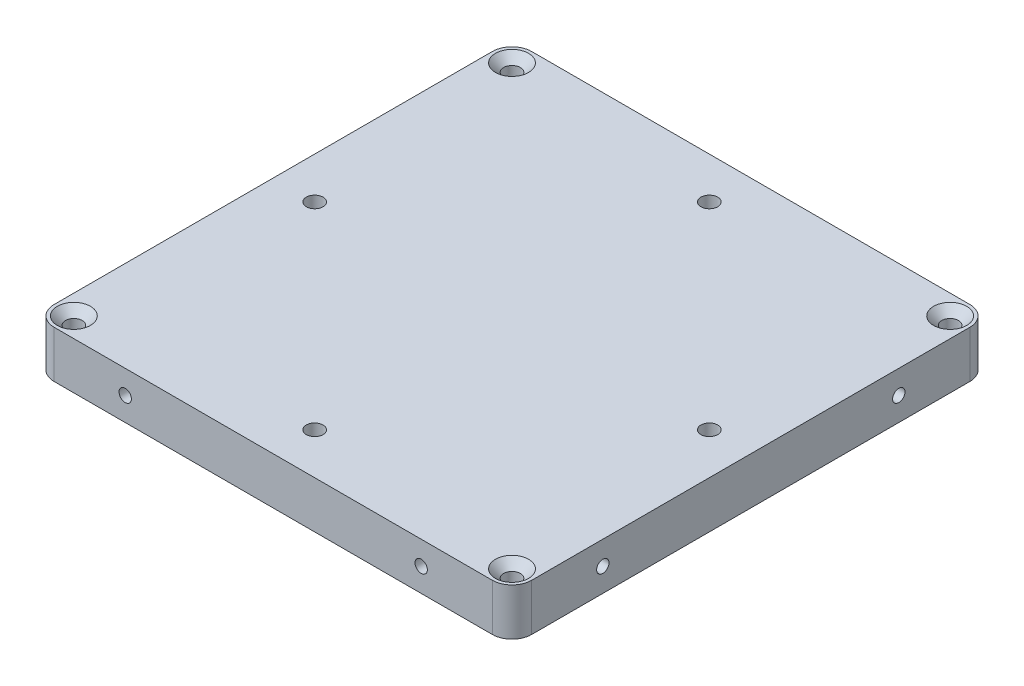
from build123d import *

# Parameters (mm, degrees)
SKETCH1_W                     = 96.825
SKETCH1_H                     = 96.825
BOSS_EXTRUDE1_DEPTH           = 4.7625
FILLET1_R                     = 4
CSK_FOR_M3_SFHCS2_D           = 3.4
CSK_FOR_M3_SFHCS2_CSINK_D     = 6.72
CSK_FOR_M3_SFHCS2_CSINK_ANGLE = 90
CSK_FOR_M3_SFHCS1_D           = 3.4
CSK_FOR_M3_SFHCS1_DEPTH       = 35
CSK_FOR_M3_SFHCS1_CSINK_D     = 6.72
CSK_FOR_M3_SFHCS1_CSINK_ANGLE = 90
CSK_FOR_M3_SFHCS1_TIP         = 1.021463052
M3X0_5_TAPPED_HOLE1_D         = 2.5
M3X0_5_TAPPED_HOLE1_DEPTH     = 10
M3X0_5_TAPPED_HOLE1_TIP       = 0.751075774
M3X0_5_TAPPED_HOLE2_D         = 2.5
M3X0_5_TAPPED_HOLE2_DEPTH     = 10
M3X0_5_TAPPED_HOLE2_TIP       = 0.751075774
M3X0_5_TAPPED_HOLE3_D         = 2.5
M3X0_5_TAPPED_HOLE3_DEPTH     = 10
M3X0_5_TAPPED_HOLE3_TIP       = 0.751075774
M3X0_5_TAPPED_HOLE4_D         = 2.5
M3X0_5_TAPPED_HOLE4_DEPTH     = 10
M3X0_5_TAPPED_HOLE4_TIP       = 0.751075774


with BuildPart() as part:
    # Sketch1 → Boss-Extrude1 (new body, symmetric)
    with BuildSketch(Plane(origin=(0, 0, 0), x_dir=(1, 0, 0), z_dir=(0, 1, 0))):
        Rectangle(SKETCH1_W, SKETCH1_H)
    extrude(amount=BOSS_EXTRUDE1_DEPTH, both=True)

    # Fillet1
    fillet1_edges = [part.edges().sort_by_distance(p)[0] for p in [
        (-48.4125, 0, -48.4125),
        (48.4125, 0, -48.4125),
        (48.4125, 0, 48.4125),
        (-48.4125, 0, 48.4125),
    ]]
    fillet(fillet1_edges, radius=FILLET1_R)

    # CSK for M3 SFHCS2 (through all)
    with Locations(Plane.XZ.offset(4.7625)):
        with Locations((-40, 0), (0, -40), (40, 0), (0, 40)):
            CounterSinkHole(CSK_FOR_M3_SFHCS2_D / 2, CSK_FOR_M3_SFHCS2_CSINK_D / 2, counter_sink_angle=CSK_FOR_M3_SFHCS2_CSINK_ANGLE)

    # CSK for M3 SFHCS1
    with Locations(Plane(origin=(0, 4.7625, 0), x_dir=(1, 0, 0), z_dir=(0, 1, 0))):
        with Locations((-44.4125, 44.4125), (44.4125, 44.4125), (44.4125, -44.4125), (-44.4125, -44.4125)):
            CounterSinkHole(CSK_FOR_M3_SFHCS1_D / 2, CSK_FOR_M3_SFHCS1_CSINK_D / 2, depth=CSK_FOR_M3_SFHCS1_DEPTH, counter_sink_angle=CSK_FOR_M3_SFHCS1_CSINK_ANGLE)
            with Locations((0, 0, -(CSK_FOR_M3_SFHCS1_DEPTH + CSK_FOR_M3_SFHCS1_TIP / 2))):  # 118° drill point
                Cone(0, CSK_FOR_M3_SFHCS1_D / 2, CSK_FOR_M3_SFHCS1_TIP, mode=Mode.SUBTRACT)

    # M3x0.5 Tapped Hole1
    with Locations(Plane.XY.offset(48.4125)):
        with Locations((-30, 0), (30, 0)):
            Hole(M3X0_5_TAPPED_HOLE1_D / 2, depth=M3X0_5_TAPPED_HOLE1_DEPTH)
            with Locations((0, 0, -(M3X0_5_TAPPED_HOLE1_DEPTH + M3X0_5_TAPPED_HOLE1_TIP / 2))):  # 118° drill point
                Cone(0, M3X0_5_TAPPED_HOLE1_D / 2, M3X0_5_TAPPED_HOLE1_TIP, mode=Mode.SUBTRACT)

    # M3x0.5 Tapped Hole2
    with Locations(Plane.ZY.offset(48.4125)):
        with Locations((-30, 0), (30, 0)):
            Hole(M3X0_5_TAPPED_HOLE2_D / 2, depth=M3X0_5_TAPPED_HOLE2_DEPTH)
            with Locations((0, 0, -(M3X0_5_TAPPED_HOLE2_DEPTH + M3X0_5_TAPPED_HOLE2_TIP / 2))):  # 118° drill point
                Cone(0, M3X0_5_TAPPED_HOLE2_D / 2, M3X0_5_TAPPED_HOLE2_TIP, mode=Mode.SUBTRACT)

    # M3x0.5 Tapped Hole3
    with Locations(Plane(origin=(0, 0, -48.4125), x_dir=(-1, 0, 0), z_dir=(0, 0, -1))):
        with Locations((-30, 0), (30, 0)):
            Hole(M3X0_5_TAPPED_HOLE3_D / 2, depth=M3X0_5_TAPPED_HOLE3_DEPTH)
            with Locations((0, 0, -(M3X0_5_TAPPED_HOLE3_DEPTH + M3X0_5_TAPPED_HOLE3_TIP / 2))):  # 118° drill point
                Cone(0, M3X0_5_TAPPED_HOLE3_D / 2, M3X0_5_TAPPED_HOLE3_TIP, mode=Mode.SUBTRACT)

    # M3x0.5 Tapped Hole4
    with Locations(Plane(origin=(48.4125, 0, 0), x_dir=(0, 0, -1), z_dir=(1, 0, 0))):
        with Locations((-30, 0), (30, 0)):
            Hole(M3X0_5_TAPPED_HOLE4_D / 2, depth=M3X0_5_TAPPED_HOLE4_DEPTH)
            with Locations((0, 0, -(M3X0_5_TAPPED_HOLE4_DEPTH + M3X0_5_TAPPED_HOLE4_TIP / 2))):  # 118° drill point
                Cone(0, M3X0_5_TAPPED_HOLE4_D / 2, M3X0_5_TAPPED_HOLE4_TIP, mode=Mode.SUBTRACT)


solid = part.part
